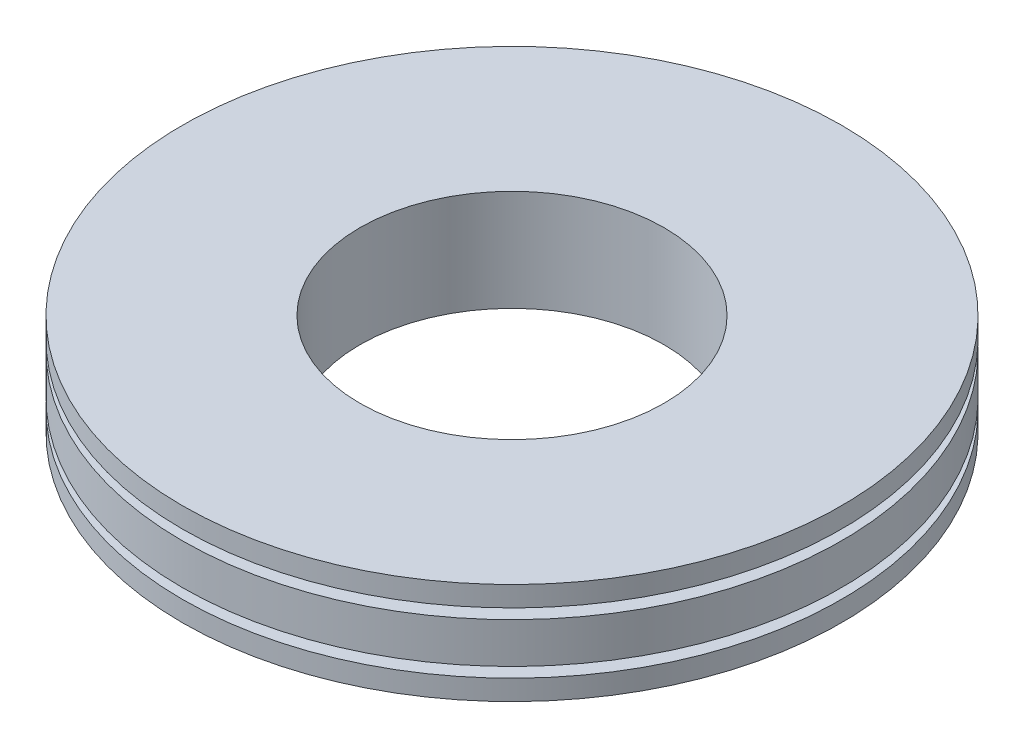
from build123d import *

# Parameters (mm, degrees)
SKETCH_1_R          = 13
EXTRUDE_1_DEPTH     = 4
SKETCH_2_R          = 6
CUT_EXTRUDE_1_DEPTH = 4
CUT_EXTRUDE_START   = -0.8
SKETCH_3_R          = 13
SKETCH_3_R_2        = 12
CUT_EXTRUDE_2_DEPTH = 0.4
CUT_EXTRUDE_START_2 = -2.8
SKETCH_3_3_R        = 13
SKETCH_3_3_R_2      = 12
CUT_EXTRUDE_3_DEPTH = 0.4


with BuildPart() as part:
    # 草图1 → 凸台-拉伸1 (new body)
    with BuildSketch(Plane(origin=(0, 0, 0), x_dir=(1, 0, 0), z_dir=(0, 1, 0))):
        Circle(SKETCH_1_R)
    extrude(amount=EXTRUDE_1_DEPTH)

    # 草图2 → 切除-拉伸1 (cut)
    with BuildSketch(Plane.XZ):
        Circle(SKETCH_2_R)
    extrude(amount=-CUT_EXTRUDE_1_DEPTH, mode=Mode.SUBTRACT)

    # 草图3 → 切除-拉伸2 (cut)
    with BuildSketch(Plane.XZ.offset(CUT_EXTRUDE_START)):
        Circle(SKETCH_3_R)
        Circle(SKETCH_3_R_2, mode=Mode.SUBTRACT)
    extrude(amount=-CUT_EXTRUDE_2_DEPTH, mode=Mode.SUBTRACT)

    # 草图3<3> → 切除-拉伸3 (cut)
    with BuildSketch(Plane.XZ.offset(CUT_EXTRUDE_START_2)):
        Circle(SKETCH_3_3_R)
        Circle(SKETCH_3_3_R_2, mode=Mode.SUBTRACT)
    extrude(amount=-CUT_EXTRUDE_3_DEPTH, mode=Mode.SUBTRACT)


solid = part.part
